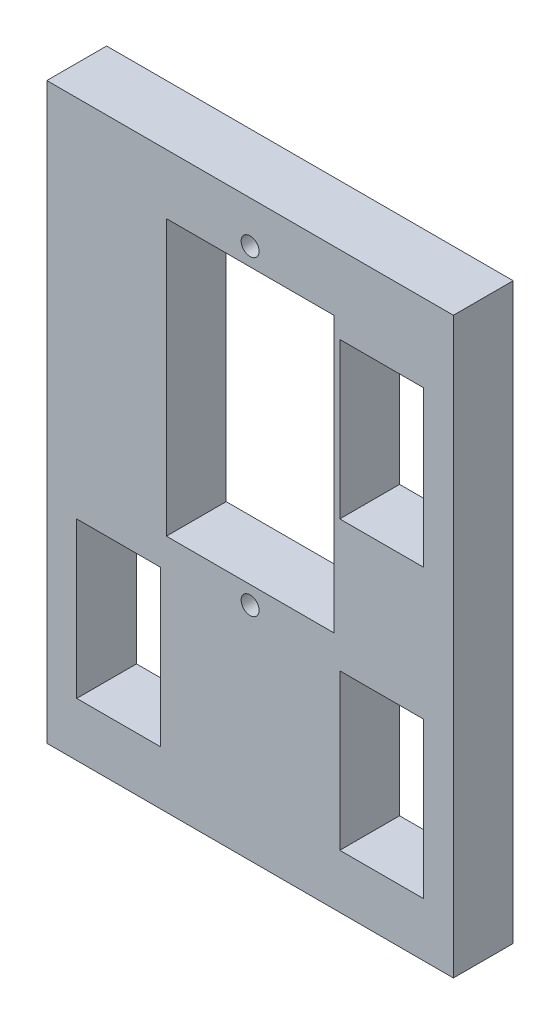
from build123d import *

# Parameters (mm, degrees)
CROQUIS1_W              = 34
CROQUIS1_H              = 48
CROQUIS1_R              = 0.75
CROQUIS1_W_2            = 14
CROQUIS1_H_2            = 23
CROQUIS1_W_3            = 7
CROQUIS1_H_3            = 13
SALIENTE_EXTRUIR1_DEPTH = 5


with BuildPart() as part:
    # Croquis1 → Saliente-Extruir1 (new body)
    with BuildSketch(Plane.XY):
        with Locations((17, 24)):
            Rectangle(CROQUIS1_W, CROQUIS1_H)
        with Locations((17, 18.5)):
            Circle(CROQUIS1_R, mode=Mode.SUBTRACT)
        with Locations((17, 44.5)):
            Circle(CROQUIS1_R, mode=Mode.SUBTRACT)
        with Locations((17, 31.5)):
            Rectangle(CROQUIS1_W_2, CROQUIS1_H_2, mode=Mode.SUBTRACT)
        with Locations((28, 11)):
            Rectangle(CROQUIS1_W_3, CROQUIS1_H_3, mode=Mode.SUBTRACT)
        with Locations((28, 35)):
            Rectangle(CROQUIS1_W_3, CROQUIS1_H_3, mode=Mode.SUBTRACT)
        with Locations((6, 11)):
            Rectangle(CROQUIS1_W_3, CROQUIS1_H_3, mode=Mode.SUBTRACT)
    extrude(amount=SALIENTE_EXTRUIR1_DEPTH)


solid = part.part
